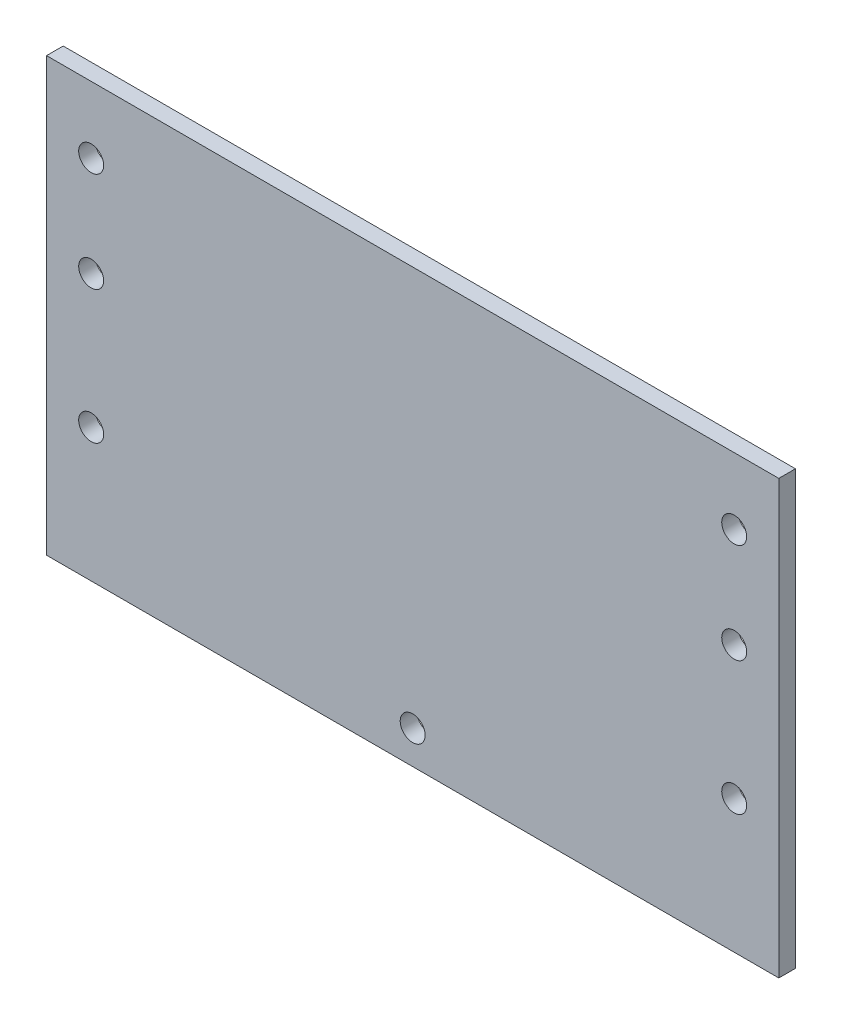
from build123d import *

# Parameters (mm, degrees)
SKETCH1_W           = 558.8
SKETCH1_H           = 330.2
BOSS_EXTRUDE1_DEPTH = 12.7
SKETCH4_R           = 9.525
CUT_EXTRUDE1_DEPTH  = 12.7


with BuildPart() as part:
    # Sketch1 → Boss-Extrude1 (new body)
    with BuildSketch(Plane.XY):
        with Locations((279.4, -165.1)):
            Rectangle(SKETCH1_W, SKETCH1_H)
    extrude(amount=BOSS_EXTRUDE1_DEPTH)

    # Sketch4 → Cut-Extrude1 (cut)
    with BuildSketch(Plane(origin=(0, 0, 0), x_dir=(-1, 0, 0), z_dir=(0, 0, -1))):
        with Locations((-279.4, -304.8)):
            Circle(SKETCH4_R)
        with Locations((-524.764, -228.6)):
            Circle(SKETCH4_R)
        with Locations((-524.764, -127)):
            Circle(SKETCH4_R)
        with Locations((-34.036, -228.6)):
            Circle(SKETCH4_R)
        with Locations((-34.036, -127)):
            Circle(SKETCH4_R)
        with Locations((-524.764, -50.8)):
            Circle(SKETCH4_R)
        with Locations((-34.036, -50.8)):
            Circle(SKETCH4_R)
    extrude(amount=-CUT_EXTRUDE1_DEPTH, mode=Mode.SUBTRACT)


solid = part.part
